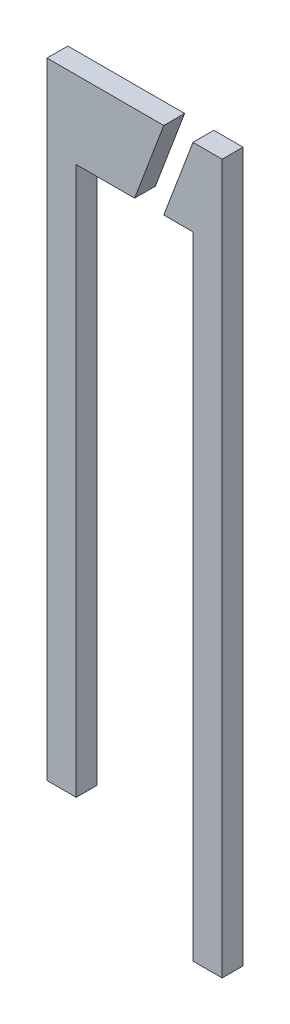
from build123d import *

# Parameters (mm, degrees)
BOSS_EXTRUDE1_DEPTH   = 0.5
BOSS_EXTRUDE1_2_DEPTH = 0.5


with BuildPart() as part:
    # Sketch1 → Boss-Extrude1 (new body)
    with BuildSketch(Plane.XY):
        Polygon((1.4, 5.283641161), (0.7, 3.42348285), (1.4, 3.42348285), (1.4, -11.716358839), (2.1, -11.716358839), (2.1, 5.283641161), align=None)
    extrude(amount=BOSS_EXTRUDE1_DEPTH)


with BuildPart() as body_2:
    # Sketch1 → Boss-Extrude1 2 (new body)
    with BuildSketch(Plane.XY):
        Polygon((-2.1, -9.716358839), (-1.4, -9.716358839), (-1.4, 3.42348285), (0, 3.42348285), (0.7, 5.283641161), (-2.1, 5.283641161), align=None)
    extrude(amount=BOSS_EXTRUDE1_2_DEPTH)


solid = Compound([part.part, body_2.part])
